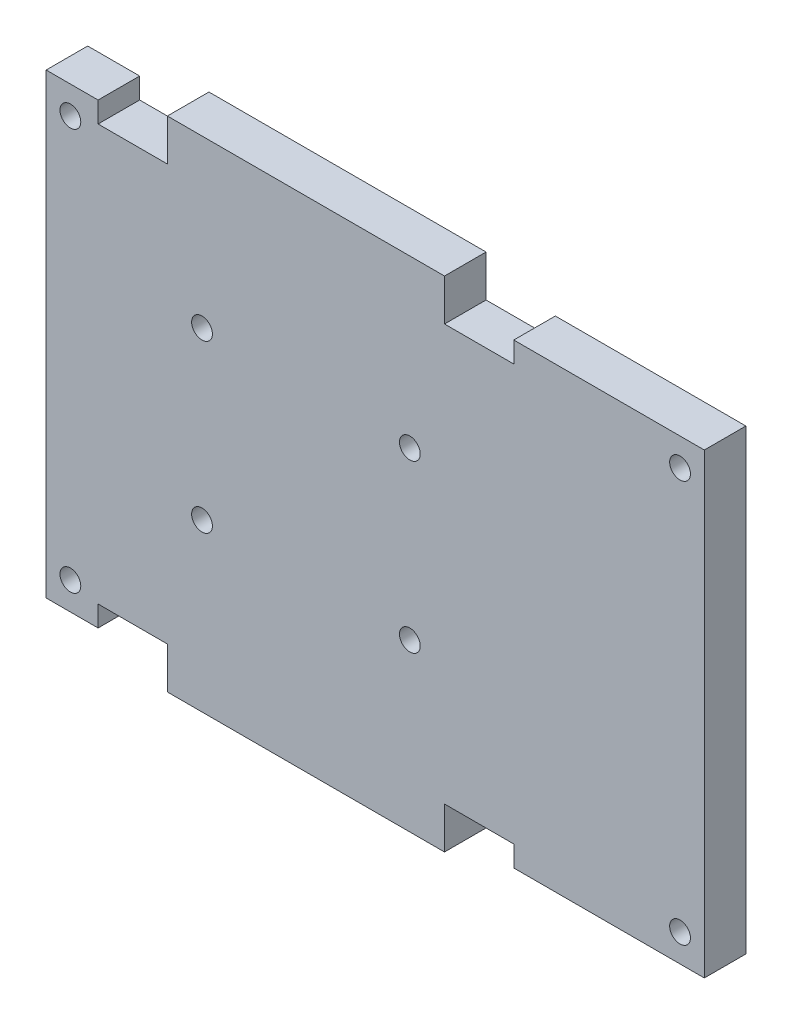
from build123d import *

# Parameters (mm, degrees)
SKETCH1_W               = 60
SKETCH1_H               = 72
BOSS_EXTRUDE1_DEPTH     = 6
SKETCH2_W               = 10
SKETCH2_H               = 6
CUT_EXTRUDE1_DEPTH      = 1
CUT_EXTRUDE1_DEPTH_BACK = 7
SKETCH3_R               = 1.5
CUT_EXTRUDE2_DEPTH      = 1
CUT_EXTRUDE2_DEPTH_BACK = 7
SKETCH6_W               = 6
SKETCH6_H               = 66
BOSS_EXTRUDE2_DEPTH     = 27.5
SKETCH7_W               = 6
SKETCH7_H               = 66
BOSS_EXTRUDE3_DEPTH     = 7.5
SKETCH8_R               = 1.5
CUT_EXTRUDE3_DEPTH      = 7


with BuildPart() as part:
    # Sketch1 → Boss-Extrude1 (new body)
    with BuildSketch(Plane.XY):
        Rectangle(SKETCH1_W, SKETCH1_H)
    extrude(amount=BOSS_EXTRUDE1_DEPTH)

    # Sketch2 → Cut-Extrude1 (cut, two sides)
    with BuildSketch(Plane.XY.offset(6)) as cut_extrude1_sk:
        with Locations((-25, 33)):
            Rectangle(SKETCH2_W, SKETCH2_H)
        with Locations((-25, -33)):
            Rectangle(SKETCH2_W, SKETCH2_H)
        with Locations((25, -33)):
            Rectangle(SKETCH2_W, SKETCH2_H)
        with Locations((25, 33)):
            Rectangle(SKETCH2_W, SKETCH2_H)
    extrude(amount=CUT_EXTRUDE1_DEPTH, mode=Mode.SUBTRACT)
    extrude(cut_extrude1_sk.sketch, amount=-CUT_EXTRUDE1_DEPTH_BACK, mode=Mode.SUBTRACT)

    # Sketch3 → Cut-Extrude2 (cut, two sides)
    with BuildSketch(Plane.XY.offset(6)) as cut_extrude2_sk:
        with Locations((-15, 12)):
            Circle(SKETCH3_R)
        with Locations((-15, -12)):
            Circle(SKETCH3_R)
        with Locations((15, -12)):
            Circle(SKETCH3_R)
        with Locations((15, 12)):
            Circle(SKETCH3_R)
    extrude(amount=CUT_EXTRUDE2_DEPTH, mode=Mode.SUBTRACT)
    extrude(cut_extrude2_sk.sketch, amount=-CUT_EXTRUDE2_DEPTH_BACK, mode=Mode.SUBTRACT)

    # Sketch6 → Boss-Extrude2 (add)
    with BuildSketch(Plane(origin=(30, 0, 0), x_dir=(0, 0, -1), z_dir=(1, 0, 0))):
        with Locations((-3, 0)):
            Rectangle(SKETCH6_W, SKETCH6_H)
    extrude(amount=BOSS_EXTRUDE2_DEPTH)

    # Sketch7 → Boss-Extrude3 (add)
    with BuildSketch(Plane.ZY.offset(30)):
        with Locations((3, 0)):
            Rectangle(SKETCH7_W, SKETCH7_H)
    extrude(amount=BOSS_EXTRUDE3_DEPTH)

    # Sketch8 → Cut-Extrude3 (cut, through all)
    with BuildSketch(Plane.XY.offset(6)):
        with Locations((54, -29)):
            Circle(SKETCH8_R)
        with Locations((54, 29)):
            Circle(SKETCH8_R)
        with Locations((-34, 29)):
            Circle(SKETCH8_R)
        with Locations((-34, -29)):
            Circle(SKETCH8_R)
    extrude(amount=-CUT_EXTRUDE3_DEPTH, mode=Mode.SUBTRACT)


solid = part.part
